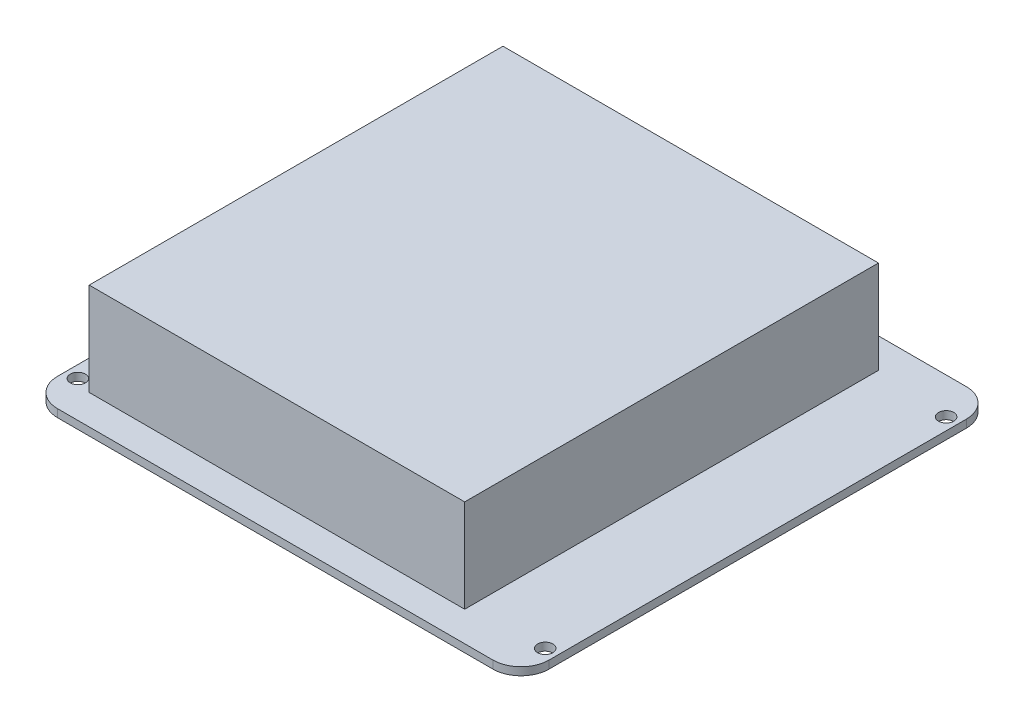
from build123d import *

# Parameters (mm, degrees)
SKETCH1_W           = 99.910000078
SKETCH1_H           = 96.25
SKETCH1_R           = 1.55
BOSS_EXTRUDE1_DEPTH = 1.6
FILLET1_R           = 5.7
SKETCH2_W           = 76.33
SKETCH2_H           = 84.11
BOSS_EXTRUDE2_DEPTH = 18.9
SKETCH3_W           = 6.96
SKETCH3_H           = 6.55
BOSS_EXTRUDE3_DEPTH = 5.15


with BuildPart() as part:
    # Sketch1 → Boss-Extrude1 (new body)
    with BuildSketch(Plane(origin=(0, 0, 0), x_dir=(1, 0, 0), z_dir=(0, 1, 0))):
        Rectangle(SKETCH1_W, SKETCH1_H)
        with Locations((-47.5, 40.75)):
            Circle(SKETCH1_R, mode=Mode.SUBTRACT)
        with Locations((47.5, 40.75)):
            Circle(SKETCH1_R, mode=Mode.SUBTRACT)
        with Locations((-47.5, -40.75)):
            Circle(SKETCH1_R, mode=Mode.SUBTRACT)
        with Locations((47.5, -40.75)):
            Circle(SKETCH1_R, mode=Mode.SUBTRACT)
    extrude(amount=BOSS_EXTRUDE1_DEPTH)

    # Fillet1
    fillet1_edges = [part.edges().sort_by_distance(p)[0] for p in [
        (-49.955000039, 0.8, -48.125),
        (49.955000039, 0.8, -48.125),
        (49.955000039, 0.8, 48.125),
        (-49.955000039, 0.8, 48.125),
    ]]
    fillet(fillet1_edges, radius=FILLET1_R)

    # Sketch2 → Boss-Extrude2 (add)
    with BuildSketch(Plane(origin=(0, 1.6, 0), x_dir=(1, 0, 0), z_dir=(0, 1, 0))):
        with Locations((-5.730000039, 0)):
            Rectangle(SKETCH2_W, SKETCH2_H)
    extrude(amount=BOSS_EXTRUDE2_DEPTH)

    # Sketch3 → Boss-Extrude3 (add)
    with BuildSketch(Plane.XZ):
        with Locations((-10.615000039, 2.95)):
            Rectangle(SKETCH3_W, SKETCH3_H)
    extrude(amount=BOSS_EXTRUDE3_DEPTH)


solid = part.part
